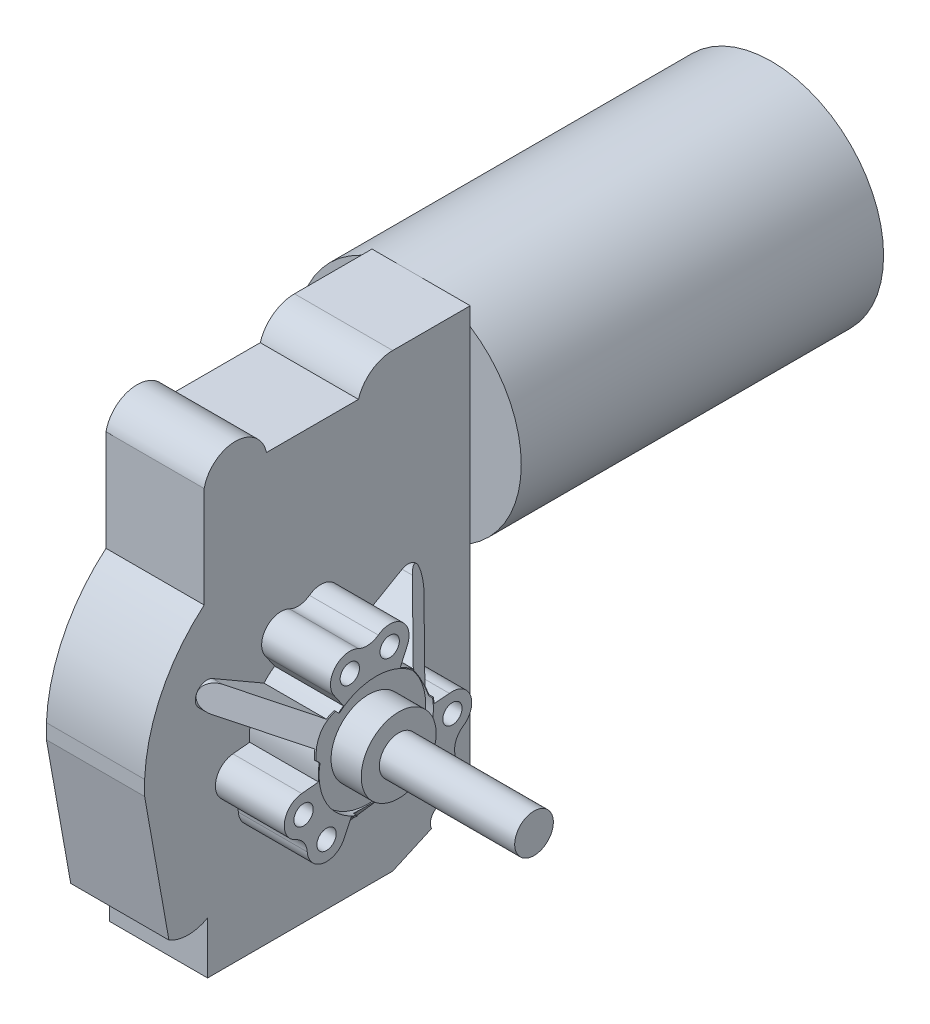
from build123d import *

# Parameters (mm, degrees)
SKETCH1_R           = 36.83
BOSS_EXTRUDE1_DEPTH = 118.999
BOSS_EXTRUDE2_DEPTH = 106.934
SKETCH5_R           = 3.175
BOSS_EXTRUDE3_DEPTH = 42.672
SKETCH6_R           = 12.3063
BOSS_EXTRUDE4_DEPTH = 7.366
SKETCH7_R           = 6.35
BOSS_EXTRUDE5_DEPTH = 44.45
CUT_EXTRUDE1_DEPTH  = 6.35
CIRPATTERN1_COUNT   = 3
SKETCH9_R           = 18.778489943
SKETCH9_R_2         = 12.3063
CUT_EXTRUDE3_DEPTH  = 2.54
CUT_EXTRUDE5_DEPTH  = 64.516
SKETCH11_W          = 106.934
SKETCH11_H          = 172.212
SKETCH11_R          = 19.05
CUT_EXTRUDE6_DEPTH  = 5.08


with BuildPart() as part:
    # Sketch1 → Boss-Extrude1 (new body)
    with BuildSketch(Plane.XY):
        Circle(SKETCH1_R)
    extrude(amount=BOSS_EXTRUDE1_DEPTH)

    # Sketch2 → Boss-Extrude2 (add)
    with BuildSketch(Plane.XY.offset(118.999)):
        Polygon((-17.272, -111.252), (0, -111.252), (20.066, -111.252), (20.066, 36.83), (0, 36.83), (-17.272, 36.83), align=None)
    extrude(amount=BOSS_EXTRUDE2_DEPTH)

    # Sketch5 → Boss-Extrude3 (add)
    with BuildSketch(Plane(origin=(0, 0, 0), x_dir=(0, 0, -1), z_dir=(1, 0, 0))):
        with BuildLine():
            Line((-161.397522513, -64.780557592), (-158.176657009, -69.292297782))
            ThreePointArc((-158.176657009, -69.292297782), (-150.748546887, -71.537048486), (-146.695301399, -64.919879399))
            ThreePointArc((-146.695301399, -64.919879399), (-146.137186102, -61.553327551), (-143.917007364, -58.961808613))
            ThreePointArc((-143.917007364, -58.961808613), (-141.537508816, -51.375240527), (-148.430626829, -47.412545395))
            Line((-148.430626829, -47.412545395), (-153.472996527, -47.803478665))
            ThreePointArc((-153.472996527, -47.803478665), (-153.795004902, -45.494936389), (-154.396538982, -43.243000868))
            Line((-154.396538982, -43.243000868), (-137.565432116, -33.525556788))
            ThreePointArc((-137.565432116, -33.525556788), (-136.170875327, -28.321), (-141.375432116, -26.926443212))
            Line((-141.375432116, -26.926443212), (-158.206538982, -36.643887292))
            ThreePointArc((-158.206538982, -36.643887292), (-161.142571632, -33.956650471), (-164.572897994, -31.938138519))
            Line((-164.572897994, -31.938138519), (-162.276049127, -26.892917075))
            ThreePointArc((-162.276049127, -26.892917075), (-164.046093053, -19.337609656), (-171.803352327, -19.135980639))
            ThreePointArc((-171.803352327, -19.135980639), (-174.997929399, -20.335914537), (-178.352340003, -19.708942818))
            ThreePointArc((-178.352340003, -19.708942818), (-186.112249967, -21.44152067), (-186.097485612, -29.392483547))
            Line((-186.097485612, -29.392483547), (-183.23774262, -33.563837166))
            ThreePointArc((-183.23774262, -33.563837166), (-185.07599469, -34.996975736), (-186.725461018, -36.643887292))
            Line((-186.725461018, -36.643887292), (-203.556567884, -26.926443212))
            ThreePointArc((-203.556567884, -26.926443212), (-208.761124673, -28.321), (-207.366567884, -33.525556788))
            Line((-207.366567884, -33.525556788), (-190.535461018, -43.243000868))
            ThreePointArc((-190.535461018, -43.243000868), (-191.394660046, -47.12929814), (-191.427579493, -51.109303889))
            Line((-191.427579493, -51.109303889), (-196.945293864, -51.642785143))
            ThreePointArc((-196.945293864, -51.642785143), (-202.60336006, -56.953341858), (-198.899346274, -63.772139962))
            ThreePointArc((-198.899346274, -63.772139962), (-196.262884499, -65.938757912), (-195.128652633, -69.157248569))
            ThreePointArc((-195.128652633, -69.157248569), (-189.748241217, -75.011238802), (-182.869887559, -71.022971058))
            Line((-182.869887559, -71.022971058), (-180.687260853, -66.460684169))
            ThreePointArc((-180.687260853, -66.460684169), (-178.527000408, -67.336087875), (-176.276, -67.94111184))
            Line((-176.276, -67.94111184), (-176.276, -87.376))
            ThreePointArc((-176.276, -87.376), (-172.466, -91.186), (-168.656, -87.376))
            Line((-168.656, -87.376), (-168.656, -67.94111184))
            ThreePointArc((-168.656, -67.94111184), (-164.860768323, -66.742051389), (-161.397522513, -64.780557592))
        make_face()
        with Locations(Location((-196.334192568, -57.96331164, 0), (0, 0, 180))):
            Circle(SKETCH5_R, mode=Mode.SUBTRACT)
        with Locations(Location((-188.792805286, -68.733528855, 0), (0, 0, 180))):
            Circle(SKETCH5_R, mode=Mode.SUBTRACT)
        with Locations(Location((-153.008471145, -65.602805286, 0), (0, 0, 180))):
            Circle(SKETCH5_R, mode=Mode.SUBTRACT)
        with Locations(Location((-181.15331164, -25.407807432, 0), (0, 0, 180))):
            Circle(SKETCH5_R, mode=Mode.SUBTRACT)
        with Locations(Location((-147.451883073, -53.686663713, 0), (0, 0, 180))):
            Circle(SKETCH5_R, mode=Mode.SUBTRACT)
        with Locations(Location((-168.055336287, -24.261883073, 0), (0, 0, 180))):
            Circle(SKETCH5_R, mode=Mode.SUBTRACT)
    extrude(amount=BOSS_EXTRUDE3_DEPTH)

    # Sketch6 → Boss-Extrude4 (add)
    with BuildSketch(Plane(origin=(42.672, 0, 0), x_dir=(0, 0, -1), z_dir=(1, 0, 0))):
        with Locations((-172.466, -49.276)):
            Circle(SKETCH6_R)
    extrude(amount=BOSS_EXTRUDE4_DEPTH)

    # Sketch7 → Boss-Extrude5 (add)
    with BuildSketch(Plane(origin=(50.038, 0, 0), x_dir=(0, 0, -1), z_dir=(1, 0, 0))):
        with Locations((-172.466, -49.276)):
            Circle(SKETCH7_R)
    extrude(amount=BOSS_EXTRUDE5_DEPTH)

    # Sketch8 → Cut-Extrude1 (cut, symmetric)
    with BuildSketch(Plane.XY.offset(172.466)):
        Polygon((33.984536572, -91.186), (42.672, -91.186), (42.672, -65.558528855), (20.066, -91.186), align=None)
    cut_extrude1 = extrude(amount=CUT_EXTRUDE1_DEPTH, both=True, mode=Mode.SUBTRACT)

    # CirPattern1: Cut-Extrude1 ×3 about axis
    cirpattern1_axis = Axis((0, -49.276, 172.466), (1, 0, 0))
    for i in range(1, CIRPATTERN1_COUNT):
        add(cut_extrude1.rotate(cirpattern1_axis, i * 360 / CIRPATTERN1_COUNT), mode=Mode.SUBTRACT)

    # Sketch9 → Cut-Extrude3 (cut)
    with BuildSketch(Plane(origin=(42.672, 0, 0), x_dir=(0, 0, -1), z_dir=(1, 0, 0))):
        with Locations((-172.466, -49.276)):
            Circle(SKETCH9_R)
        with Locations((-172.466, -49.276)):
            Circle(SKETCH9_R_2, mode=Mode.SUBTRACT)
    extrude(amount=-CUT_EXTRUDE3_DEPTH, mode=Mode.SUBTRACT)

    # Sketch10 → Cut-Extrude5 (cut)
    with BuildSketch(Plane(origin=(20.066, 0, 0), x_dir=(0, 0, -1), z_dir=(1, 0, 0))):
        with BuildLine():
            ThreePointArc((-196.140161944, 36.83), (-189.556049093, 34.498981945), (-185.905323889, 28.544454869))
            Line((-185.905323889, 28.544454869), (-155.698336218, 28.544454869))
            ThreePointArc((-155.698336218, 28.544454869), (-151.442912399, 34.534613017), (-144.462810316, 36.83))
            Line((-144.462810316, 36.83), (-196.140161944, 36.83))
        make_face()
        with BuildLine():
            Line((-225.933, 36.83), (-196.140161944, 36.83))
            Line((-196.140161944, 36.83), (-144.462810316, 36.83))
            Line((-144.462810316, 36.83), (-118.999, 36.83))
            Line((-118.999, 36.83), (-118.999, 50.647128775))
            Line((-118.999, 50.647128775), (-241.488177292, 47.370933918))
            Line((-241.488177292, 47.370933918), (-248.161188723, -133.541820439))
            Line((-248.161188723, -133.541820439), (-101.17840725, -130.594797251))
            Line((-101.17840725, -130.594797251), (-97.863006164, -40.710590035))
            Line((-97.863006164, -40.710590035), (-118.999, -36.83))
            Line((-118.999, -36.83), (-118.999, -99.905236761))
            Line((-118.999, -99.905236761), (-118.999, -111.252))
            Line((-118.999, -111.252), (-144.462810316, -111.252))
            Line((-144.462810316, -111.252), (-205.254201052, -111.252))
            Line((-205.254201052, -111.252), (-225.933, -111.252))
            Line((-225.933, -111.252), (-225.933, -49.276))
            ThreePointArc((-225.933, -49.276), (-225.98633544, -46.848001509), (-225.933, -44.420003018))
            Line((-225.933, -44.420003018), (-225.933, 36.83))
        make_face()
        with BuildLine():
            ThreePointArc((-206.375, 28.544454869), (-202.724274795, 34.498981945), (-196.140161944, 36.83))
            Line((-196.140161944, 36.83), (-225.933, 36.83))
            Line((-225.933, 36.83), (-225.933, -44.420003018))
            ThreePointArc((-225.933, -44.420003018), (-220.320950995, -22.467647817), (-206.375, -4.609555989))
            Line((-206.375, -4.609555989), (-206.375, 28.544454869))
        make_face()
        with BuildLine():
            Line((-217.954201052, -94.125385307), (-225.933, -49.276))
            Line((-225.933, -49.276), (-225.933, -111.252))
            Line((-225.933, -111.252), (-205.254201052, -111.252))
            Line((-205.254201052, -111.252), (-205.254201052, -94.125385307))
            ThreePointArc((-205.254201052, -94.125385307), (-211.604201052, -95.826862679), (-217.954201052, -94.125385307))
        make_face()
        with BuildLine():
            Line((-131.730905158, -105.545100158), (-144.462810316, -111.252))
            Line((-144.462810316, -111.252), (-118.999, -111.252))
            Line((-118.999, -111.252), (-118.999, -99.905236761))
            Line((-118.999, -99.905236761), (-128.078378287, -99.905236761))
            ThreePointArc((-128.078378287, -99.905236761), (-131.438029001, -101.732105713), (-131.730905158, -105.545100158))
        make_face()
    extrude(amount=-CUT_EXTRUDE5_DEPTH, mode=Mode.SUBTRACT)

    # Sketch11 → Cut-Extrude6 (cut)
    with BuildSketch(Plane.ZY.offset(17.272)):
        with Locations((172.466, -49.276)):
            Rectangle(SKETCH11_W, SKETCH11_H)
        with Locations((172.466, -49.276)):
            Circle(SKETCH11_R, mode=Mode.SUBTRACT)
    extrude(amount=-CUT_EXTRUDE6_DEPTH, mode=Mode.SUBTRACT)


solid = part.part
